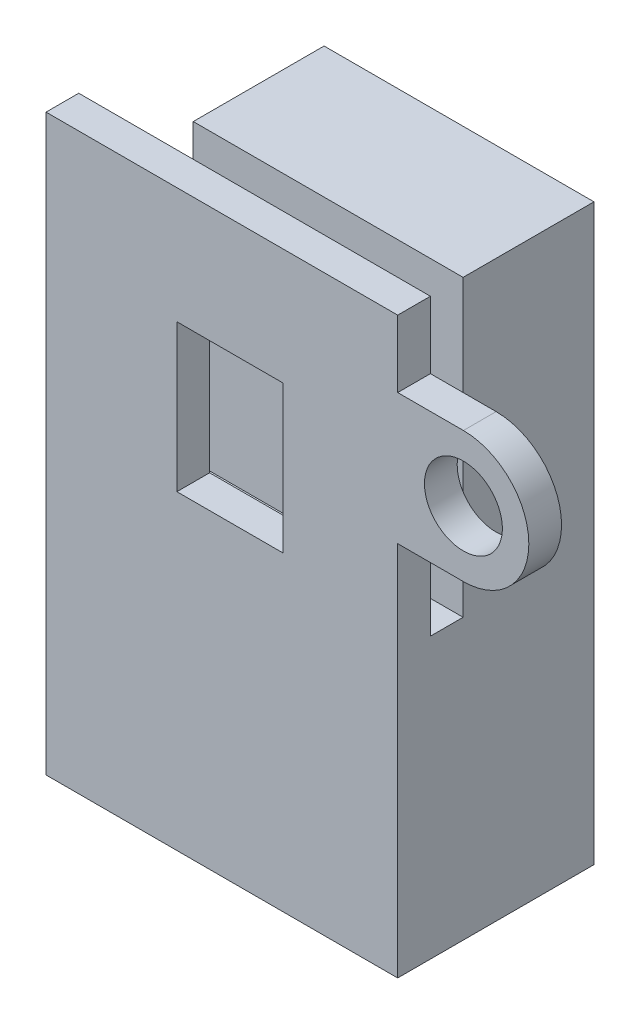
from build123d import *

# Parameters (mm, degrees)
BOSS_EXTRUDE4_DEPTH = 16.5
CUT_EXTRUDE2_DEPTH  = 1.5
CUT_EXTRUDE4_DEPTH  = 17.5
SKETCH6_W           = 12
SKETCH6_H           = 2
CUT_EXTRUDE5_DEPTH  = 17.5
BOSS_EXTRUDE5_DEPTH = 2
SKETCH10_R          = 2.38125
CUT_EXTRUDE6_DEPTH  = 13.606601718
CUT_EXTRUDE7_DEPTH  = 17.5
SKETCH12_R          = 2.38125
CUT_EXTRUDE8_DEPTH  = 6.35
SKETCH13_W          = 6.5
SKETCH13_H          = 9
CUT_EXTRUDE11_DEPTH = 2
SKETCH15_W          = 16.5
SKETCH15_H          = 2
CUT_EXTRUDE13_DEPTH = 18
SKETCH16_W          = 2
SKETCH16_H          = 35.1
BOSS_EXTRUDE6_DEPTH = 5


with BuildPart() as part:
    # Sketch1 → Boss-Extrude4 (new body)
    with BuildSketch(Plane(origin=(0, 0, 0), x_dir=(0, 0, -1), z_dir=(1, 0, 0))):
        Polygon((0, 0), (0, 37.1), (-10.606601718, 47.706601718), (12, 47.706601718), (12, 0), align=None)
    extrude(amount=BOSS_EXTRUDE4_DEPTH)

    # Sketch4 → Cut-Extrude2 (cut)
    with BuildSketch(Plane.ZY):
        Polygon((0, 37.1), (0, 47.706601718), (10.606601718, 47.706601718), align=None)
    extrude(amount=-CUT_EXTRUDE2_DEPTH, mode=Mode.SUBTRACT)

    # Sketch5 → Cut-Extrude4 (cut, through all)
    with BuildSketch(Plane(origin=(16.5, 0, 0), x_dir=(0, 0, -1), z_dir=(1, 0, 0))):
        Polygon((-3.566952421, 40.666952421), (-2.859845639, 39.959845639), (-1.799185468, 41.020505811), (0, 39.221320344), (0, 42.756854249), (-2.683068944, 45.439923194), (-4.450835897, 43.672156241), (-3.036622335, 42.257942678), (-4.097282506, 41.197282506), align=None)
    extrude(amount=-CUT_EXTRUDE4_DEPTH, mode=Mode.SUBTRACT)

    # Sketch6 → Cut-Extrude5 (cut, through all)
    with BuildSketch(Plane(origin=(16.5, 0, 0), x_dir=(0, 0, -1), z_dir=(1, 0, 0))):
        with Locations((6, 1)):
            Rectangle(SKETCH6_W, SKETCH6_H)
    extrude(amount=-CUT_EXTRUDE5_DEPTH, mode=Mode.SUBTRACT)

    # Sketch9 → Boss-Extrude5 (add)
    with BuildSketch(Plane.XY):
        with BuildLine():
            Line((16.5, 29), (16.5, 25))
            Line((16.5, 25), (20.518219338, 25))
            ThreePointArc((20.518219338, 25), (24.518219338, 29), (20.518219338, 33))
            Line((20.518219338, 33), (16.5, 33))
            Line((16.5, 33), (16.5, 29))
        make_face()
    extrude(amount=-BOSS_EXTRUDE5_DEPTH)

    # Sketch10 → Cut-Extrude6 (cut, through all)
    with BuildSketch(Plane(origin=(0, 0, -2), x_dir=(-1, 0, 0), z_dir=(0, 0, -1))):
        with Locations((-20.518219338, 29)):
            Circle(SKETCH10_R)
    extrude(amount=-CUT_EXTRUDE6_DEPTH, mode=Mode.SUBTRACT)

    # Sketch11 → Cut-Extrude7 (cut, through all)
    with BuildSketch(Plane(origin=(16.5, 0, 0), x_dir=(0, 0, -1), z_dir=(1, 0, 0))):
        Polygon((0, 37.1), (-10.606601718, 47.706601718), (12, 47.706601718), (12, 37.1), align=None)
    extrude(amount=-CUT_EXTRUDE7_DEPTH, mode=Mode.SUBTRACT)

    # Sketch12 → Cut-Extrude8 (cut)
    with BuildSketch(Plane.XZ.offset(-2)):
        with Locations((8.25, -6)):
            Circle(SKETCH12_R)
    extrude(amount=-CUT_EXTRUDE8_DEPTH, mode=Mode.SUBTRACT)

    # Sketch13 → Cut-Extrude11 (cut)
    with BuildSketch(Plane.XY):
        with Locations((6.25, 25.5)):
            Rectangle(SKETCH13_W, SKETCH13_H)
    extrude(amount=-CUT_EXTRUDE11_DEPTH, mode=Mode.SUBTRACT)

    # Sketch15 → Cut-Extrude13 (cut)
    with BuildSketch(Plane(origin=(0, 37.1, 0), x_dir=(1, 0, 0), z_dir=(0, 1, 0))):
        with Locations((8.25, 3)):
            Rectangle(SKETCH15_W, SKETCH15_H)
    extrude(amount=-CUT_EXTRUDE13_DEPTH, mode=Mode.SUBTRACT)

    # Sketch16 → Boss-Extrude6 (add)
    with BuildSketch(Plane.ZY):
        with Locations((-1, 19.55)):
            Rectangle(SKETCH16_W, SKETCH16_H)
    extrude(amount=BOSS_EXTRUDE6_DEPTH)


solid = part.part
